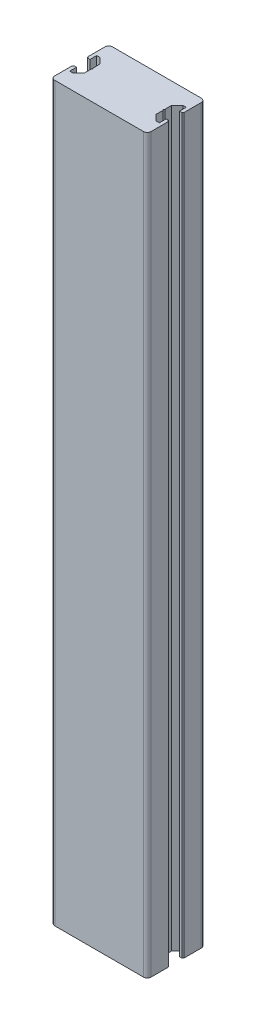
from build123d import *

# Parameters (mm, degrees)
BOSS_EXTRUDE1_DEPTH = 570
FILLET1_R           = 3
SKETCH2_R           = 1.5
CUT_EXTRUDE1_DEPTH  = 10


with BuildPart() as part:
    # Sketch1 → Boss-Extrude1 (new body)
    with BuildSketch(Plane(origin=(0, 0, 0), x_dir=(1, 0, 0), z_dir=(0, 1, 0))):
        with BuildLine():
            Line((2.625, 17.250000178), (0.75, 17.250000178))
            ThreePointArc((0.75, 17.250000178), (0.530330086, 16.719670092), (0, 16.500000178))
            Line((0, 16.500000178), (0, 0))
            Line((0, 0), (75, 0))
            Line((75, 0), (75, 16.500000178))
            ThreePointArc((75, 16.500000178), (74.469669914, 16.719670092), (74.25, 17.250000178))
            Line((74.25, 17.250000178), (72.375, 17.250000178))
            Line((72.375, 17.250000178), (72.375, 12.000000178))
            Line((72.375, 12.000000178), (69.75, 12.000000178))
            Line((69.75, 12.000000178), (65.375, 16.375))
            Line((65.375, 16.375), (65.375, 21.75))
            Line((65.375, 21.75), (64.625, 22.5))
            Line((64.625, 22.5), (65.375, 23.25))
            Line((65.375, 23.25), (65.375, 28.625))
            Line((65.375, 28.625), (69.75, 33.000000178))
            Line((69.75, 33.000000178), (72.375, 33.000000178))
            Line((72.375, 33.000000178), (72.375, 27.750000178))
            Line((72.375, 27.750000178), (74.25, 27.750000178))
            ThreePointArc((74.25, 27.750000178), (74.469669914, 28.280330264), (75, 28.500000178))
            Line((75, 28.500000178), (75, 45))
            Line((75, 45), (0, 45))
            Line((0, 45), (0, 28.500000178))
            ThreePointArc((0, 28.500000178), (0.530330086, 28.280330264), (0.75, 27.750000178))
            Line((0.75, 27.750000178), (2.625, 27.750000178))
            Line((2.625, 27.750000178), (2.625, 33.000000178))
            Line((2.625, 33.000000178), (5.25, 33.000000178))
            Line((5.25, 33.000000178), (9.625, 28.625))
            Line((9.625, 28.625), (9.625, 23.25))
            Line((9.625, 23.25), (10.375, 22.5))
            Line((10.375, 22.5), (9.625, 21.75))
            Line((9.625, 21.75), (9.625, 16.375))
            Line((9.625, 16.375), (5.25, 12.000000178))
            Line((5.25, 12.000000178), (2.625, 12.000000178))
            Line((2.625, 12.000000178), (2.625, 17.250000178))
        make_face()
    extrude(amount=BOSS_EXTRUDE1_DEPTH)

    # Fillet1
    fillet1_edges = [part.edges().sort_by_distance(p)[0] for p in [
        (0, 285, 0),
        (0, 285, -45),
        (75, 285, -45),
        (75, 285, 0),
    ]]
    fillet(fillet1_edges, radius=FILLET1_R)

    # Sketch2 → Cut-Extrude1 (cut)
    with BuildSketch(Plane(origin=(0, 0, -45), x_dir=(-1, 0, 0), z_dir=(0, 0, -1))):
        with Locations((-6.5, 48)):
            Circle(SKETCH2_R)
        with Locations((-6.5, 8)):
            Circle(SKETCH2_R)
        with Locations((-68.5, 48)):
            Circle(SKETCH2_R)
        with Locations((-68.5, 8)):
            Circle(SKETCH2_R)
        with Locations((-68.5, 562)):
            Circle(SKETCH2_R)
        with Locations((-68.5, 522)):
            Circle(SKETCH2_R)
        with Locations((-68.5, 462)):
            Circle(SKETCH2_R)
        with Locations((-68.5, 422)):
            Circle(SKETCH2_R)
        with Locations((-68.5, 362)):
            Circle(SKETCH2_R)
        with Locations((-68.5, 322)):
            Circle(SKETCH2_R)
        with Locations((-6.5, 362)):
            Circle(SKETCH2_R)
        with Locations((-6.5, 322)):
            Circle(SKETCH2_R)
    extrude(amount=-CUT_EXTRUDE1_DEPTH, mode=Mode.SUBTRACT)


solid = part.part
